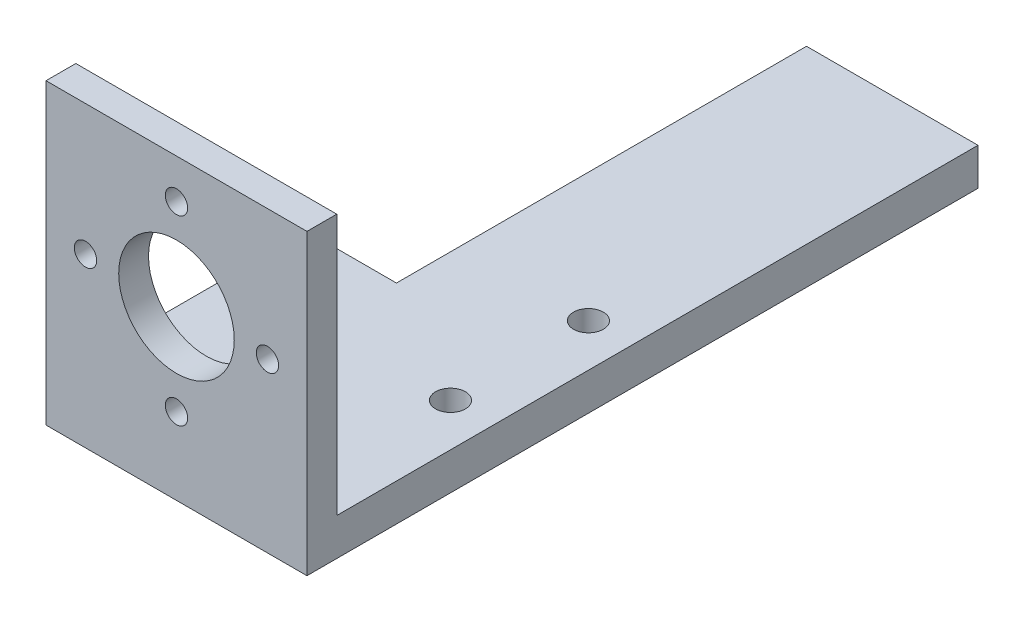
from build123d import *

# Parameters (mm, degrees)
SKETCH1_R           = 2
BOSS_EXTRUDE1_DEPTH = 2.5
SKETCH2_W           = 35
SKETCH2_H           = 4
BOSS_EXTRUDE2_DEPTH = 35
CUT_EXTRUDE1_REACH  = 6
SKETCH3_R           = 1.5
SKETCH3_R_2         = 7.75


with BuildPart() as part:
    # Sketch1 → Boss-Extrude1 (new body, symmetric)
    with BuildSketch(Plane(origin=(0, 0, 0), x_dir=(1, 0, 0), z_dir=(0, 1, 0))):
        Polygon((17.5, 45), (-5.5, 45), (-5.5, -10), (-17.5, -10), (-17.5, -45), (17.5, -45), align=None)
        with Locations((-11.75, -20)):
            Circle(SKETCH1_R, mode=Mode.SUBTRACT)
        with BuildLine():
            ThreePointArc((13.75, -20), (11.75, -22), (9.75, -20))
            ThreePointArc((9.75, -20), (11.75, -18), (13.75, -20))
        make_face(mode=Mode.SUBTRACT)
        with Locations((11.75, -1.5)):
            Circle(SKETCH1_R, mode=Mode.SUBTRACT)
    extrude(amount=BOSS_EXTRUDE1_DEPTH, both=True)

    # Sketch2 → Boss-Extrude2 (add)
    with BuildSketch(Plane(origin=(0, 2.5, 0), x_dir=(1, 0, 0), z_dir=(0, 1, 0))):
        with Locations((0, -43)):
            Rectangle(SKETCH2_W, SKETCH2_H)
    extrude(amount=BOSS_EXTRUDE2_DEPTH)

    # Sketch3 → Cut-Extrude1 (cut, up to next)
    with BuildSketch(Plane(origin=(0, 0, 41), x_dir=(-1, 0, 0), z_dir=(0, 0, -1)), mode=Mode.PRIVATE) as cut_extrude1_sk1:
        with Locations((-12.2, 20)):
            Circle(SKETCH3_R)
    cut_extrude1_tool1 = extrude(cut_extrude1_sk1.sketch, amount=-CUT_EXTRUDE1_REACH, mode=Mode.PRIVATE) & part.part
    add(cut_extrude1_tool1.solids().sort_by_distance((12.2, 20, 41))[0], mode=Mode.SUBTRACT)
    # Sketch3 → Cut-Extrude1 (cut, up to next)
    with BuildSketch(Plane(origin=(0, 0, 41), x_dir=(-1, 0, 0), z_dir=(0, 0, -1)), mode=Mode.PRIVATE) as cut_extrude1_sk2:
        with Locations((0, 32.2)):
            Circle(SKETCH3_R)
    cut_extrude1_tool2 = extrude(cut_extrude1_sk2.sketch, amount=-CUT_EXTRUDE1_REACH, mode=Mode.PRIVATE) & part.part
    add(cut_extrude1_tool2.solids().sort_by_distance((0, 32.2, 41))[0], mode=Mode.SUBTRACT)
    # Sketch3 → Cut-Extrude1 (cut, up to next)
    with BuildSketch(Plane(origin=(0, 0, 41), x_dir=(-1, 0, 0), z_dir=(0, 0, -1)), mode=Mode.PRIVATE) as cut_extrude1_sk3:
        with Locations((12.2, 20)):
            Circle(SKETCH3_R)
    cut_extrude1_tool3 = extrude(cut_extrude1_sk3.sketch, amount=-CUT_EXTRUDE1_REACH, mode=Mode.PRIVATE) & part.part
    add(cut_extrude1_tool3.solids().sort_by_distance((-12.2, 20, 41))[0], mode=Mode.SUBTRACT)
    # Sketch3 → Cut-Extrude1 (cut, up to next)
    with BuildSketch(Plane(origin=(0, 0, 41), x_dir=(-1, 0, 0), z_dir=(0, 0, -1)), mode=Mode.PRIVATE) as cut_extrude1_sk4:
        with Locations((0, 20)):
            Circle(SKETCH3_R_2)
    cut_extrude1_tool4 = extrude(cut_extrude1_sk4.sketch, amount=-CUT_EXTRUDE1_REACH, mode=Mode.PRIVATE) & part.part
    add(cut_extrude1_tool4.solids().sort_by_distance((0, 20, 41))[0], mode=Mode.SUBTRACT)
    # Sketch3 → Cut-Extrude1 (cut, up to next)
    with BuildSketch(Plane(origin=(0, 0, 41), x_dir=(-1, 0, 0), z_dir=(0, 0, -1)), mode=Mode.PRIVATE) as cut_extrude1_sk5:
        with Locations((0, 7.8)):
            Circle(SKETCH3_R)
    cut_extrude1_tool5 = extrude(cut_extrude1_sk5.sketch, amount=-CUT_EXTRUDE1_REACH, mode=Mode.PRIVATE) & part.part
    add(cut_extrude1_tool5.solids().sort_by_distance((0, 7.8, 41))[0], mode=Mode.SUBTRACT)


solid = part.part
